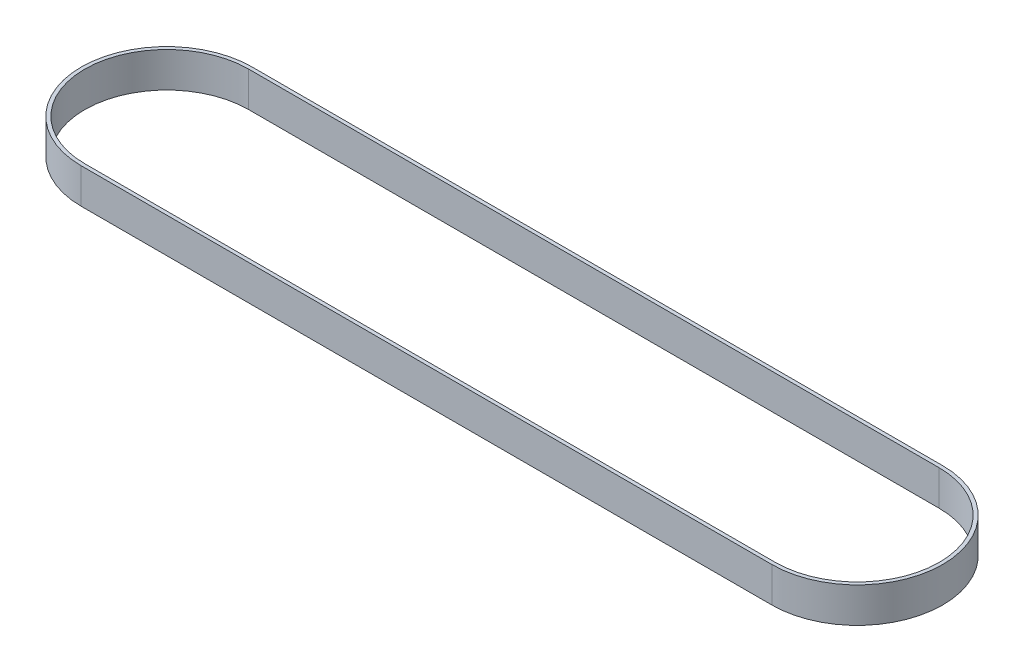
from build123d import *

# Parameters (mm, degrees)
BOSS_EXTRUDE1_DEPTH = 15


with BuildPart() as part:
    # Sketch1 → Boss-Extrude1 (new body)
    with BuildSketch(Plane(origin=(0, 0, 0), x_dir=(1, 0, 0), z_dir=(0, 1, 0))):
        with BuildLine():
            Line((0, -36.5379), (295.0718, -36.5379))
            ThreePointArc((295.0718, -36.5379), (331.6097, 0), (295.0718, 36.5379))
            Line((295.0718, 36.5379), (0, 36.5379))
            ThreePointArc((0, 36.5379), (-36.5379, 0), (0, -36.5379))
        make_face()
        with BuildLine():
            Line((0, 35.0139), (295.0718, 35.0139))
            ThreePointArc((295.0718, 35.0139), (330.0857, 0), (295.0718, -35.0139))
            Line((295.0718, -35.0139), (0, -35.0139))
            ThreePointArc((0, -35.0139), (-35.0139, 0), (0, 35.0139))
        make_face(mode=Mode.SUBTRACT)
    extrude(amount=BOSS_EXTRUDE1_DEPTH)


solid = part.part
